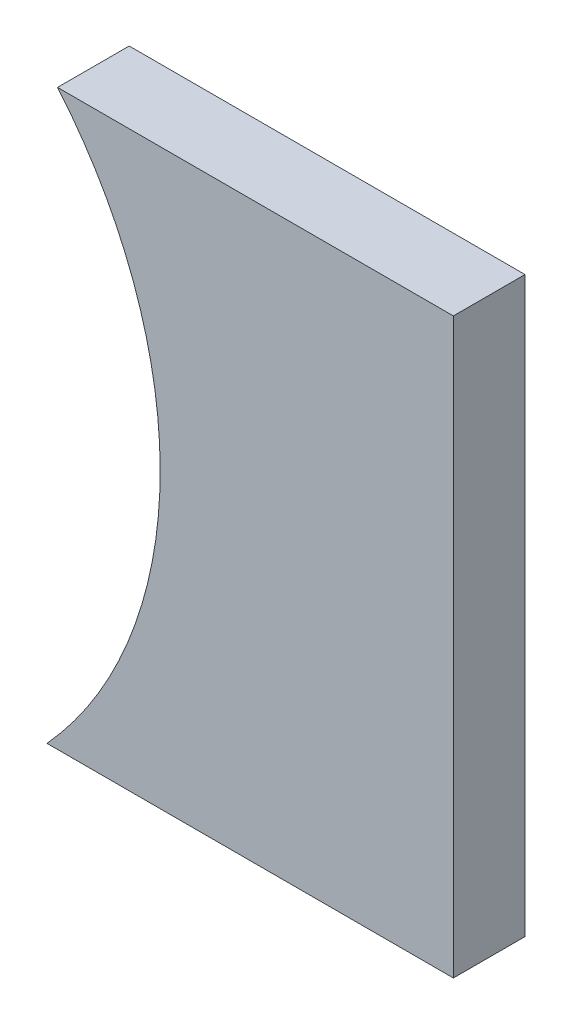
from build123d import *

# Parameters (mm, degrees)
DODANIE_WYCI_GNI_CIE1_DEPTH = 2
SZKIC2_W                    = 5
SZKIC2_H                    = 16
WYTNIJ_WYCI_GNI_CIE1_DEPTH  = 5
WYTNIJ_WYCI_GNI_CIE2_DEPTH  = 10
WYTNIJ_WYCI_GNI_CIE3_DEPTH  = 10


with BuildPart() as part:
    # Szkic1 → Dodanie-wyciągnięcie1 (new body)
    with BuildSketch(Plane.XY):
        Polygon((39.660703644, 7.348041155), (39.998203889, -8.651958845), (67.367690874, -8.651958845), (67.367690874, 7.348041155), align=None)
    extrude(amount=-DODANIE_WYCI_GNI_CIE1_DEPTH)

    # Szkic2 → Wytnij-wyciągnięcie1 (cut)
    with BuildSketch(Plane.XY):
        with Locations((64.867690874, -0.651958845)):
            Rectangle(SZKIC2_W, SZKIC2_H)
    extrude(amount=-WYTNIJ_WYCI_GNI_CIE1_DEPTH, mode=Mode.SUBTRACT)

    # Szkic3 → Wytnij-wyciągnięcie2 (cut)
    with BuildSketch(Plane.XY):
        with BuildLine():
            Line((39.660703644, 7.348041155), (39.998203889, -8.651958845))
            Line((39.998203889, -8.651958845), (48.125210145, -8.651958845))
            ThreePointArc((48.125210145, -8.651958845), (51.694710699, -0.869414217), (49.289973229, 7.348041155))
            Line((49.289973229, 7.348041155), (39.660703644, 7.348041155))
        make_face()
    extrude(amount=-WYTNIJ_WYCI_GNI_CIE2_DEPTH, mode=Mode.SUBTRACT)

    # Szkic4 → Wytnij-wyciągnięcie3 (cut)
    with BuildSketch(Plane.XY):
        with BuildLine():
            Line((48.125210145, -8.651958845), (51.027201312, -8.651958845))
            ThreePointArc((51.027201312, -8.651958845), (54.184885403, -0.707437008), (51.322077756, 7.348041155))
            Line((51.322077756, 7.348041155), (49.289973229, 7.348041155))
            Line((49.289973229, 7.348041155), (48.125210145, -8.651958845))
        make_face()
    extrude(amount=-WYTNIJ_WYCI_GNI_CIE3_DEPTH, mode=Mode.SUBTRACT)


solid = part.part
